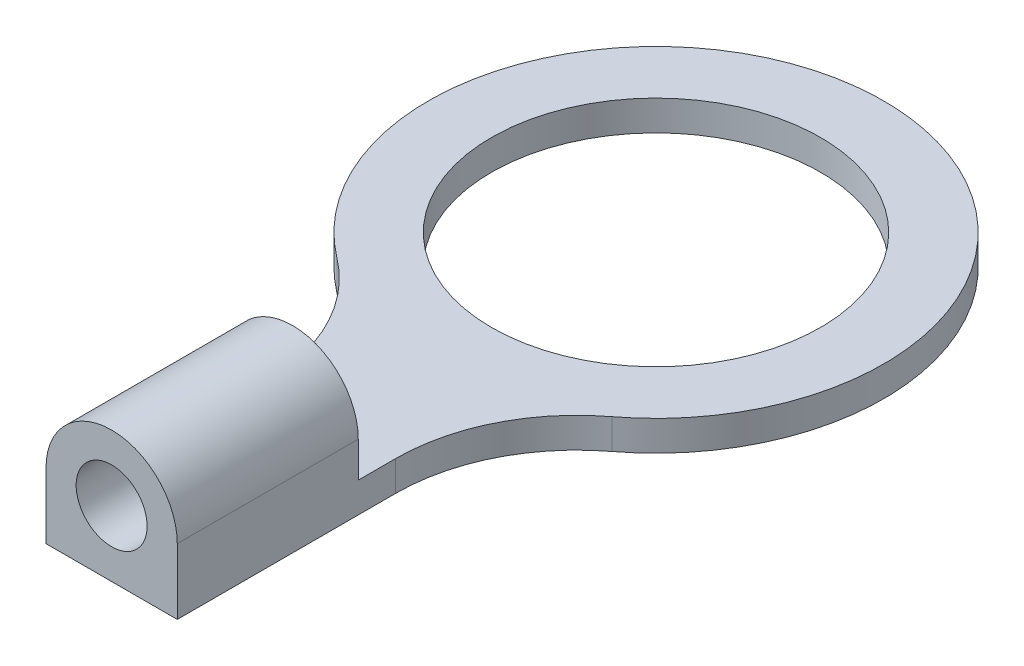
from build123d import *

# Parameters (mm, degrees)
SKETCH1_R           = 4.3307
BOSS_EXTRUDE1_DEPTH = 0.79375
SKETCH2_R           = 0.93345
BOSS_EXTRUDE2_DEPTH = 4.7625


with BuildPart() as part:
    # Sketch1 → Boss-Extrude1 (new body)
    with BuildSketch(Plane(origin=(0, 0, 0), x_dir=(1, 0, 0), z_dir=(0, 1, 0))):
        with BuildLine():
            Line((-1.7272, -14.3256), (1.7272, -14.3256))
            Line((1.7272, -14.3256), (1.7272, -8.578734844))
            ThreePointArc((1.7272, -8.578734844), (2.225592247, -6.457699407), (3.616456198, -4.780593679))
            ThreePointArc((3.616456198, -4.780593679), (0, 5.9944), (-3.616456198, -4.780593679))
            ThreePointArc((-3.616456198, -4.780593679), (-2.225592247, -6.457699407), (-1.7272, -8.578734844))
            Line((-1.7272, -8.578734844), (-1.7272, -14.3256))
        make_face()
        Circle(SKETCH1_R, mode=Mode.SUBTRACT)
    extrude(amount=BOSS_EXTRUDE1_DEPTH)

    # Sketch2 → Boss-Extrude2 (add)
    with BuildSketch(Plane.XY.offset(14.3256)):
        with BuildLine():
            Line((-1.7272, 0), (-1.7272, 1.7272))
            ThreePointArc((-1.7272, 1.7272), (0, 3.4544), (1.7272, 1.7272))
            Line((1.7272, 1.7272), (1.7272, 0))
            Line((1.7272, 0), (-1.7272, 0))
        make_face()
        with Locations((0, 1.7272)):
            Circle(SKETCH2_R, mode=Mode.SUBTRACT)
    extrude(amount=-BOSS_EXTRUDE2_DEPTH)


solid = part.part
